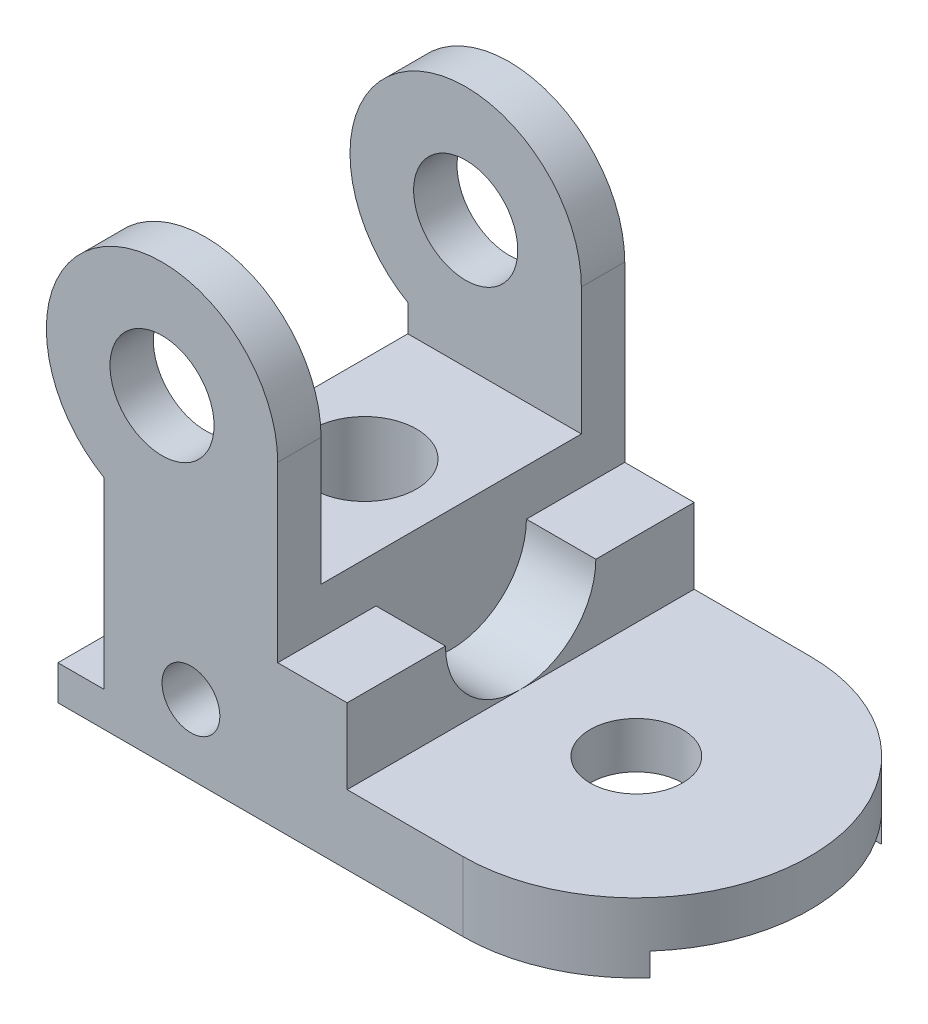
from build123d import *

# Parameters (mm, degrees)
RESSALTO_EXTRUS_O1_DEPTH    = 33
ESBO_O2_R                   = 8
CORTE_EXTRUS_O6_DEPTH       = 34
CORTE_EXTRUS_O6_DEPTH_BACK  = 1
ESBO_O5_R                   = 8
CORTE_EXTRUS_O10_DEPTH      = 21
ESBO_O5_5_W                 = 12
ESBO_O5_5_H                 = 60
CORTE_EXTRUS_O11_DEPTH      = 8
ESBO_O7_R                   = 13
CORTE_EXTRUS_O12_DEPTH      = 12
ESBO_O8_R                   = 9
RESSALTO_EXTRUS_O2_DEPTH    = 60
CORTE_EXTRUS_O13_START      = -7.5
ESBO_O8_2_R                 = 9
CORTE_EXTRUS_O13_DEPTH      = 45
ESBO_O9_W                   = 8
ESBO_O9_H                   = 27
CORTE_EXTRUS_O14_DEPTH      = 61
ESBO_O10_R                  = 9
CORTE_EXTRUS_O15_DEPTH      = 34
ESBO_O11_R                  = 5
CORTE_EXTRUS_O18_DEPTH      = 31
CORTE_EXTRUS_O18_DEPTH_BACK = 31
ESBO_O12_W                  = 20
ESBO_O12_H                  = 4
CORTE_EXTRUS_O19_DEPTH      = 101


with BuildPart() as part:
    # Esboço1 → Ressalto-extrusão1 (new body)
    with BuildSketch(Plane(origin=(0, 0, 0), x_dir=(1, 0, 0), z_dir=(0, 1, 0))):
        with BuildLine():
            Line((0, 30), (-70, 30))
            Line((-70, 30), (-70, -30))
            Line((-70, -30), (0, -30))
            ThreePointArc((0, -30), (30, 0), (0, 30))
        make_face()
    extrude(amount=RESSALTO_EXTRUS_O1_DEPTH)

    # Esboço2 → Corte-extrusão6 (cut, two sides)
    with BuildSketch(Plane(origin=(0, 0, 0), x_dir=(1, 0, 0), z_dir=(0, 1, 0))) as corte_extrus_o6_sk:
        Circle(ESBO_O2_R)
    extrude(amount=CORTE_EXTRUS_O6_DEPTH, mode=Mode.SUBTRACT)
    extrude(corte_extrus_o6_sk.sketch, amount=-CORTE_EXTRUS_O6_DEPTH_BACK, mode=Mode.SUBTRACT)

    # Esboço5 → Corte-extrusão10 (cut)
    with BuildSketch(Plane(origin=(0, 33, 0), x_dir=(1, 0, 0), z_dir=(0, 1, 0))):
        with BuildLine():
            Line((0, 30), (-20, 30))
            Line((-20, 30), (-20, -30))
            Line((-20, -30), (0, -30))
            ThreePointArc((0, -30), (30, 0), (0, 30))
        make_face()
        Circle(ESBO_O5_R, mode=Mode.SUBTRACT)
    extrude(amount=-CORTE_EXTRUS_O10_DEPTH, mode=Mode.SUBTRACT)

    # Esboço5<5> → Corte-extrusão11 (cut)
    with BuildSketch(Plane(origin=(0, 33, 0), x_dir=(1, 0, 0), z_dir=(0, 1, 0))):
        with Locations((-26, 0)):
            Rectangle(ESBO_O5_5_W, ESBO_O5_5_H)
    extrude(amount=-CORTE_EXTRUS_O11_DEPTH, mode=Mode.SUBTRACT)

    # Esboço7 → Corte-extrusão12 (cut)
    with BuildSketch(Plane(origin=(-20, 0, 0), x_dir=(0, 0, -1), z_dir=(1, 0, 0))):
        with Locations((0, 25)):
            Circle(ESBO_O7_R)
    extrude(amount=-CORTE_EXTRUS_O12_DEPTH, mode=Mode.SUBTRACT)

    # Esboço8 → Ressalto-extrusão2 (add)
    with BuildSketch(Plane.XY.offset(30)):
        with BuildLine():
            Line((-32, 33), (-32, 55))
            ThreePointArc((-32, 55), (-62, 72.320508076), (-62, 37.679491924))
            Line((-62, 37.679491924), (-62, 33))
            Line((-62, 33), (-32, 33))
        make_face()
        with Locations((-52, 55)):
            Circle(ESBO_O8_R, mode=Mode.SUBTRACT)
    extrude(amount=-RESSALTO_EXTRUS_O2_DEPTH)

    # Esboço8<2> → Corte-extrusão13 (cut)
    with BuildSketch(Plane.XY.offset(30).offset(CORTE_EXTRUS_O13_START)):
        with BuildLine():
            Line((-32, 33), (-32, 55))
            ThreePointArc((-32, 55), (-62, 72.320508076), (-62, 37.679491924))
            Line((-62, 37.679491924), (-62, 33))
            Line((-62, 33), (-32, 33))
        make_face()
        with Locations((-52, 55)):
            Circle(ESBO_O8_2_R, mode=Mode.SUBTRACT)
    extrude(amount=-CORTE_EXTRUS_O13_DEPTH, mode=Mode.SUBTRACT)

    # Esboço9 → Corte-extrusão14 (cut, through all)
    with BuildSketch(Plane.XY.offset(30)):
        with Locations((-66, 19.5)):
            Rectangle(ESBO_O9_W, ESBO_O9_H)
    extrude(amount=-CORTE_EXTRUS_O14_DEPTH, mode=Mode.SUBTRACT)

    # Esboço10 → Corte-extrusão15 (cut, through all)
    with BuildSketch(Plane(origin=(0, 33, 0), x_dir=(1, 0, 0), z_dir=(0, 1, 0))):
        with Locations((-47, 0)):
            Circle(ESBO_O10_R)
    extrude(amount=-CORTE_EXTRUS_O15_DEPTH, mode=Mode.SUBTRACT)

    # Esboço11 → Corte-extrusão18 (cut, two sides)
    with BuildSketch(Plane.XY) as corte_extrus_o18_sk:
        with Locations((-47, 12)):
            Circle(ESBO_O11_R)
    extrude(amount=CORTE_EXTRUS_O18_DEPTH, mode=Mode.SUBTRACT)
    extrude(corte_extrus_o18_sk.sketch, amount=-CORTE_EXTRUS_O18_DEPTH_BACK, mode=Mode.SUBTRACT)

    # Esboço12 → Corte-extrusão19 (cut, through all)
    with BuildSketch(Plane.ZY.offset(70)):
        with Locations((-10, 2)):
            Rectangle(ESBO_O12_W, ESBO_O12_H)
        with Locations((10, 2)):
            Rectangle(ESBO_O12_W, ESBO_O12_H)
    extrude(amount=-CORTE_EXTRUS_O19_DEPTH, mode=Mode.SUBTRACT)


solid = part.part
